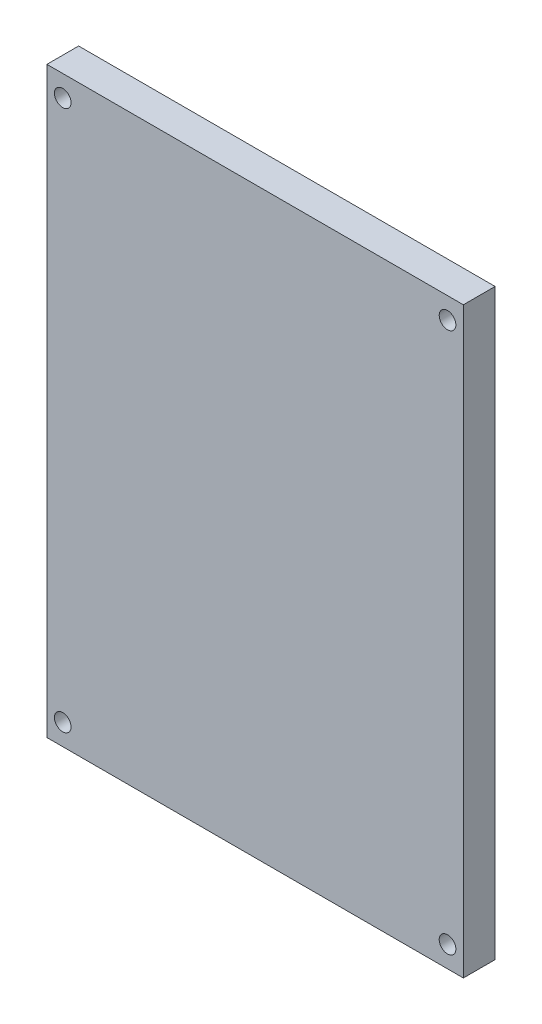
from build123d import *

# Parameters (mm, degrees)
SKETCH1_W           = 50
SKETCH1_H           = 70
BOSS_EXTRUDE1_DEPTH = 3.81
SKETCH2_R           = 1
CUT_EXTRUDE1_DEPTH  = 3.81


with BuildPart() as part:
    # Sketch1 → Boss-Extrude1 (new body)
    with BuildSketch(Plane.XY):
        with Locations((-21.821686747, -6.080722892)):
            Rectangle(SKETCH1_W, SKETCH1_H)
    extrude(amount=BOSS_EXTRUDE1_DEPTH)

    # Sketch2 → Cut-Extrude1 (cut)
    with BuildSketch(Plane.XY.offset(3.81)):
        with Locations((-44.921686747, 26.369170395)):
            Circle(SKETCH2_R)
        with Locations((1.278313253, 26.369170395)):
            Circle(SKETCH2_R)
        with Locations((1.278313253, -38.530616178)):
            Circle(SKETCH2_R)
        with Locations((-44.921686747, -38.530616178)):
            Circle(SKETCH2_R)
    extrude(amount=-CUT_EXTRUDE1_DEPTH, mode=Mode.SUBTRACT)


solid = part.part
